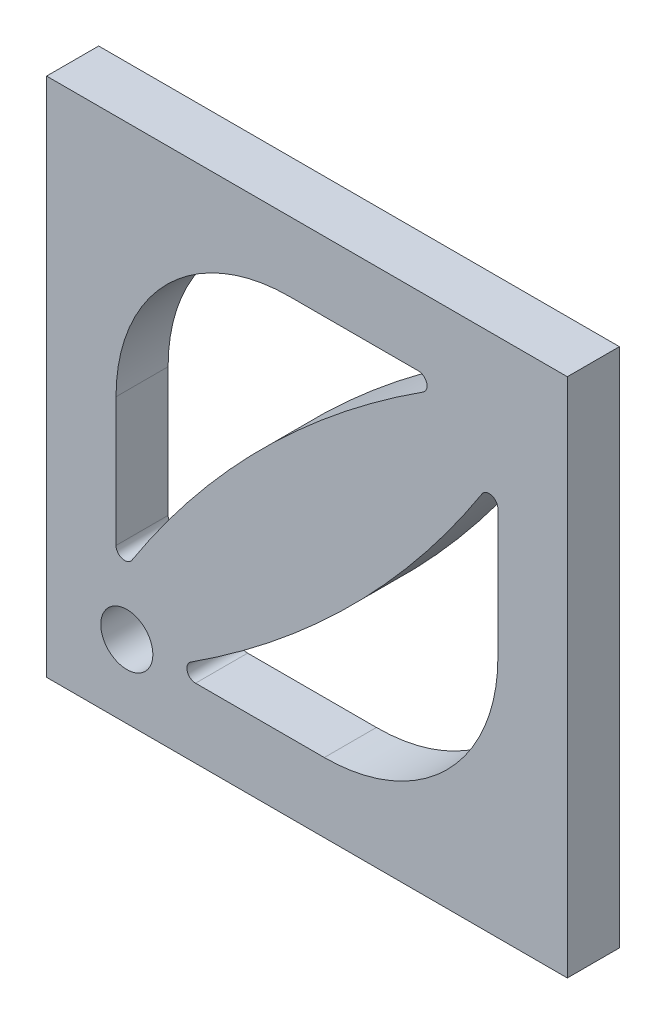
from build123d import *

# Parameters (mm, degrees)
CROQUIS1_W              = 30
CROQUIS1_H              = 30
SALIENTE_EXTRUIR1_DEPTH = 3
CROQUIS2_R              = 1.5
CORTAR_EXTRUIR1_DEPTH   = 3


with BuildPart() as part:
    # Croquis1 → Saliente-Extruir1 (new body)
    with BuildSketch(Plane.XY):
        Rectangle(CROQUIS1_W, CROQUIS1_H)
        with BuildLine():
            Line((-6.418498959, -11), (1, -11))
            ThreePointArc((1, -11), (8.071067812, -8.071067812), (11, -1))
            Line((11, -1), (11, 6.418498959))
            ThreePointArc((11, 6.418498959), (10.640885104, 6.898239917), (10.07939445, 6.688852377))
            ThreePointArc((10.07939445, 6.688852377), (2.596324807, -2.596324807), (-6.688852377, -10.07939445))
            ThreePointArc((-6.688852377, -10.07939445), (-6.898239917, -10.640885104), (-6.418498959, -11))
        make_face(mode=Mode.SUBTRACT)
        with BuildLine():
            Line((-11, -6.418498959), (-11, 1))
            ThreePointArc((-11, 1), (-8.071067812, 8.071067812), (-1, 11))
            Line((-1, 11), (6.418498959, 11))
            ThreePointArc((6.418498959, 11), (6.898239917, 10.640885104), (6.688852377, 10.07939445))
            ThreePointArc((6.688852377, 10.07939445), (-2.596324807, 2.596324807), (-10.07939445, -6.688852377))
            ThreePointArc((-10.07939445, -6.688852377), (-10.640885104, -6.898239917), (-11, -6.418498959))
        make_face(mode=Mode.SUBTRACT)
    extrude(amount=SALIENTE_EXTRUIR1_DEPTH)

    # Croquis2 → Cortar-Extruir1 (cut)
    with BuildSketch(Plane.XY.offset(3)):
        with Locations((-10.378302419, -10.798607502)):
            Circle(CROQUIS2_R)
    extrude(amount=-CORTAR_EXTRUIR1_DEPTH, mode=Mode.SUBTRACT)


solid = part.part
